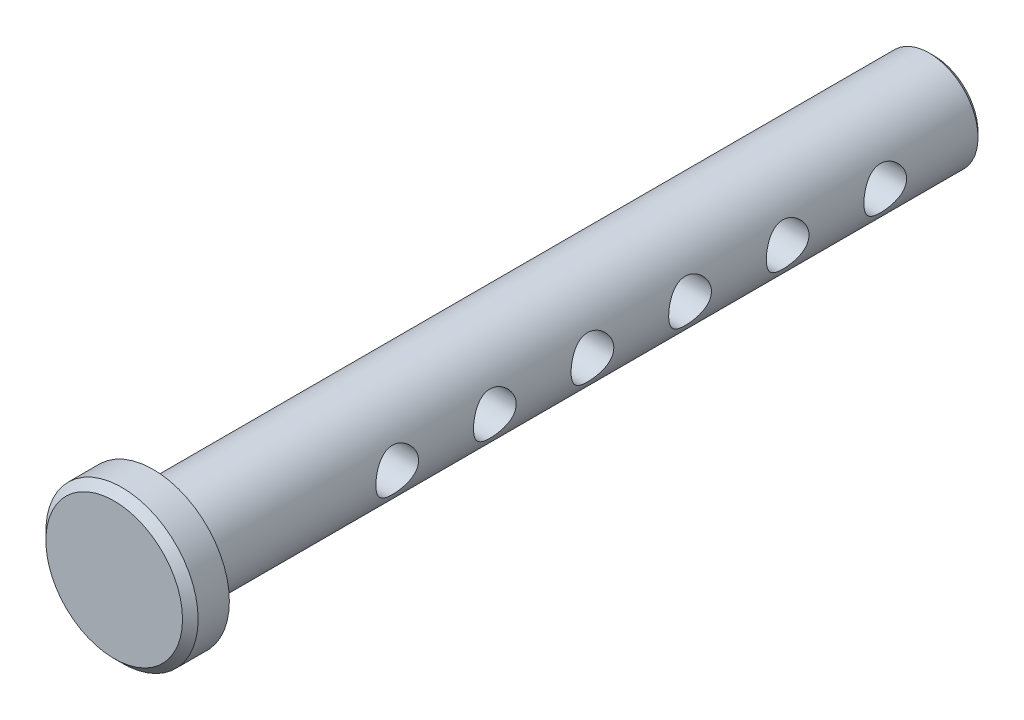
from build123d import *

# Parameters (mm, degrees)
SKETCH1_R       = 3.175
EXTRUDE1_DEPTH  = 25.4
SKETCH2_R       = 4.953
EXTRUDE2_DEPTH  = 2.54
CHAMFER1_SIZE   = 0.508
SKETCH3_R       = 1.3890625
EXTRUDE3_DEPTH  = 5.953
LPATTERN1_COUNT = 6
LPATTERN1_PITCH = 6.35
CHAMFER2_SIZE   = 0.3175


with BuildPart() as part:
    # Sketch1 → Extrude1 (new body, symmetric)
    with BuildSketch(Plane.XY):
        Circle(SKETCH1_R)
    extrude(amount=EXTRUDE1_DEPTH, both=True)

    # Sketch2 → Extrude2 (add)
    with BuildSketch(Plane.XY.offset(25.4)):
        Circle(SKETCH2_R)
    extrude(amount=EXTRUDE2_DEPTH)

    # Chamfer1
    chamfer1_edges = [part.edges().sort_by_distance(p)[0] for p in [
        (-4.953, 0, 27.94),
    ]]
    chamfer(chamfer1_edges, length=CHAMFER1_SIZE)

    # Sketch3 → Extrude3 (cut, symmetric)
    with BuildSketch(Plane(origin=(0, 0, 0), x_dir=(0, 0, -1), z_dir=(1, 0, 0))):
        with Locations((19.05, 0)):
            Circle(SKETCH3_R)
    extrude3 = extrude(amount=EXTRUDE3_DEPTH, both=True, mode=Mode.SUBTRACT)

    # LPattern1: Extrude3 ×6
    with Locations(*[(0, 0, i * LPATTERN1_PITCH) for i in range(1, LPATTERN1_COUNT)]):
        add(extrude3, mode=Mode.SUBTRACT)

    # Chamfer2
    chamfer2_edges = [part.edges().sort_by_distance(p)[0] for p in [
        (-3.175, 0, -25.4),
    ]]
    chamfer(chamfer2_edges, length=CHAMFER2_SIZE)


solid = part.part
